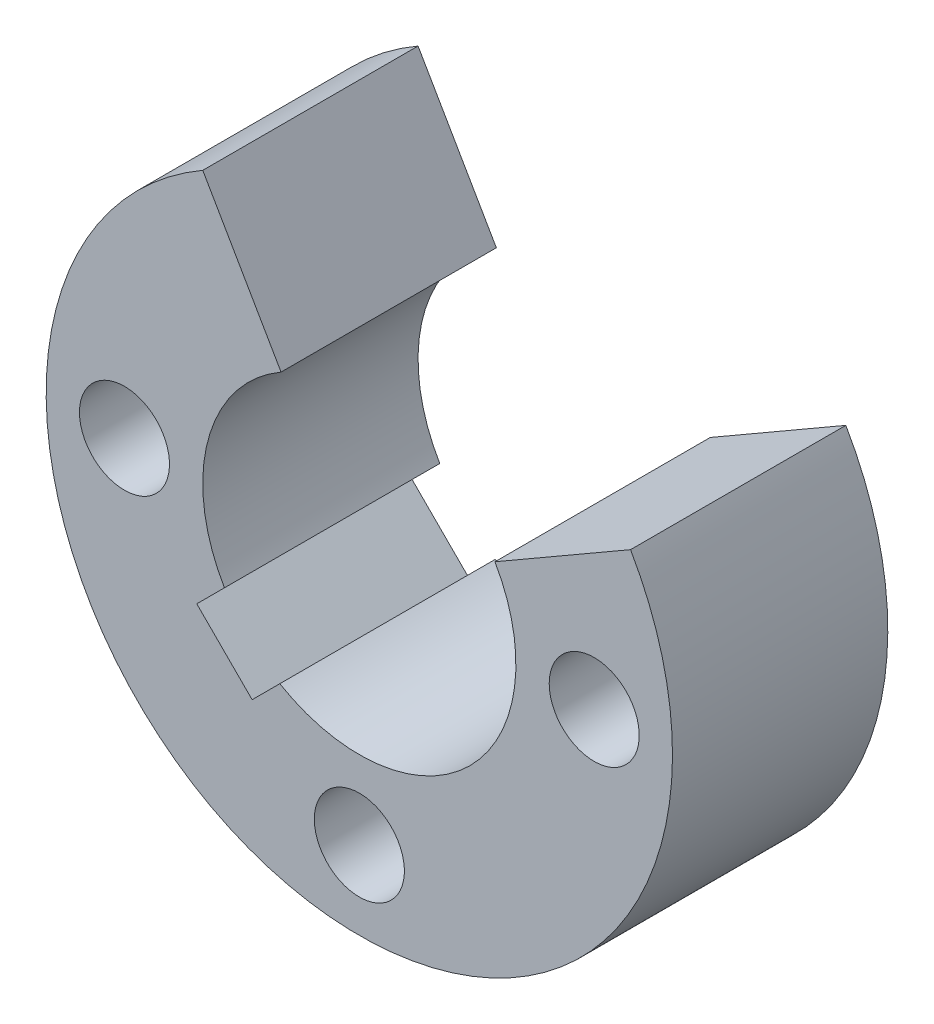
from build123d import *
from build123d.topology import SkipClean

# Parameters (mm, degrees)
SKETCH1_R           = 1.15
BOSS_EXTRUDE1_DEPTH = 8
SKETCH4_R           = 8
SKETCH4_R_2         = 1.15
BOSS_EXTRUDE2_DEPTH = 3
CUT_EXTRUDE3_DEPTH  = 5.5
SKETCH6_R           = 42
CUT_EXTRUDE5_DEPTH  = 5.5
SKETCH5_R           = 1.15
CUT_EXTRUDE6_DEPTH  = 50.185871955


with BuildPart() as part:
    # Sketch1 → Boss-Extrude1 (new body)
    with BuildSketch(Plane.XY):
        with BuildLine():
            Line((0, -42), (0, -40))
            ThreePointArc((0, -40), (22.793187837, -20.077432085), (6.099520657, 5.176470588))
            ThreePointArc((6.099520657, 5.176470588), (7.259881704, -3.360672202), (0, -8))
            ThreePointArc((0, -8), (-8, 0), (0, 8))
            ThreePointArc((0, 8), (25, -17), (0, -42))
        make_face()
        with Locations((0, 6)):
            Circle(SKETCH1_R, mode=Mode.SUBTRACT)
        with Locations((-6, 0)):
            Circle(SKETCH1_R, mode=Mode.SUBTRACT)
        with Locations((0, -6)):
            Circle(SKETCH1_R, mode=Mode.SUBTRACT)
        with Locations((6, 0)):
            Circle(SKETCH1_R, mode=Mode.SUBTRACT)
    extrude(amount=BOSS_EXTRUDE1_DEPTH)

    # Sketch4 → Boss-Extrude2 (add)
    with SkipClean():  # the faces are left unmerged after this step: merging them gives an invalid solid
        with BuildSketch(Plane(origin=(0, 0, 0), x_dir=(-1, 0, 0), z_dir=(0, 0, -1))):
            Circle(SKETCH4_R)
            with Locations((0, 6)):
                Circle(SKETCH4_R_2, mode=Mode.SUBTRACT)
            with Locations((-6, 0)):
                Circle(SKETCH4_R_2, mode=Mode.SUBTRACT)
            with Locations((0, -6)):
                Circle(SKETCH4_R_2, mode=Mode.SUBTRACT)
            with Locations((6, 0)):
                Circle(SKETCH4_R_2, mode=Mode.SUBTRACT)
        extrude(amount=BOSS_EXTRUDE2_DEPTH)

    # Sketch3 → Cut-Extrude3 (cut)
    with SkipClean():  # the faces are left unmerged after this step: merging them gives an invalid solid
        with BuildSketch(Plane.XY.offset(8)):
            with BuildLine():
                Line((6, 2), (10, 2))
                Line((10, 2), (10, -2))
                Line((10, -2), (6, -2))
                ThreePointArc((6, -2), (4, 0), (6, 2))
            make_face()
            with BuildLine():
                Line((2, -6), (2, -10))
                Line((2, -10), (-2, -10))
                Line((-2, -10), (-2, -6))
                ThreePointArc((-2, -6), (0, -4), (2, -6))
            make_face()
            with BuildLine():
                Line((-6, -2), (-10, -2))
                Line((-10, -2), (-10, 2))
                Line((-10, 2), (-6, 2))
                ThreePointArc((-6, 2), (-4, 0), (-6, -2))
            make_face()
            with BuildLine():
                Line((-2, 6), (-2, 10))
                Line((-2, 10), (2, 10))
                Line((2, 10), (2, 6))
                ThreePointArc((2, 6), (0, 4), (-2, 6))
            make_face()
        extrude(amount=-CUT_EXTRUDE3_DEPTH, mode=Mode.SUBTRACT)

    # Sketch6 → Cut-Extrude5 (cut)
    with SkipClean():  # the faces are left unmerged after this step: merging them gives an invalid solid
        with BuildSketch(Plane.XY.offset(8)):
            Circle(SKETCH6_R)
        extrude(amount=-CUT_EXTRUDE5_DEPTH, mode=Mode.SUBTRACT)

    # Sketch5 → Cut-Extrude6 (cut, through all)
    with BuildSketch(Plane(origin=(0, 0, -3), x_dir=(-1, 0, 0), z_dir=(0, 0, -1))):
        with BuildLine():
            Line((-6.92820323, 4), (-3.464101615, 2))
            ThreePointArc((-3.464101615, 2), (-2.815501367, -2.84129408), (2.031506006, -3.445719569))
            Line((2.031506006, -3.445719569), (2.738612788, -4.15282635))
            Line((2.738612788, -4.15282635), (4.15282635, -2.738612788))
            Line((4.15282635, -2.738612788), (3.445719569, -2.031506006))
            ThreePointArc((3.445719569, -2.031506006), (3.868383537, 1.017648668), (2, 3.464101615))
            Line((2, 3.464101615), (4, 6.92820323))
            ThreePointArc((4, 6.92820323), (-2.070552361, 7.72740661), (-6.92820323, 4))
        make_face()
        with Locations((0, 6)):
            Circle(SKETCH5_R, mode=Mode.SUBTRACT)
    extrude(amount=-CUT_EXTRUDE6_DEPTH, mode=Mode.SUBTRACT)


with BuildPart() as cut_extrude6_kept_piece:
    # of the separate pieces the step leaves, the one the design keeps (cut_extrude6_pieces_kept)
    add(part.part.solids().sort_by_distance((-4, 6.92820323, -3))[0])


solid = cut_extrude6_kept_piece.part
